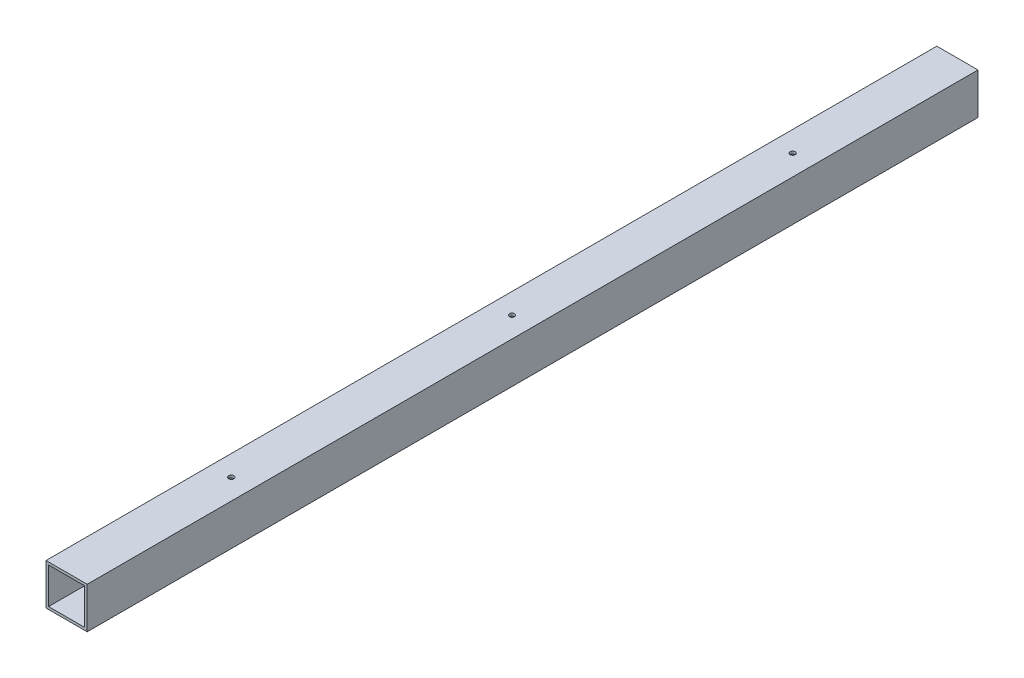
from build123d import *

# Parameters (mm, degrees)
SKETCH1_W           = 1098.55
SKETCH1_H           = 50.8
BOSS_EXTRUDE1_DEPTH = 50.8
SKETCH2_W           = 44.45
SKETCH2_H           = 44.45
CUT_EXTRUDE1_DEPTH  = 1099.55
SKETCH5_R           = 3.302
SKETCH5_R_2         = 3.175
CUT_EXTRUDE2_DEPTH  = 50.8


with BuildPart() as part:
    # Sketch1 → Boss-Extrude1 (new body)
    with BuildSketch(Plane(origin=(0, 0, 0), x_dir=(0, 0, -1), z_dir=(1, 0, 0))):
        Rectangle(SKETCH1_W, SKETCH1_H)
    extrude(amount=BOSS_EXTRUDE1_DEPTH)

    # Sketch2 → Cut-Extrude1 (cut, through all)
    with BuildSketch(Plane.XY.offset(549.275)):
        with Locations((25.4, 0)):
            Rectangle(SKETCH2_W, SKETCH2_H)
    extrude(amount=-CUT_EXTRUDE1_DEPTH, mode=Mode.SUBTRACT)

    # Sketch5 → Cut-Extrude2 (cut)
    with BuildSketch(Plane(origin=(0, 25.4, 0), x_dir=(1, 0, 0), z_dir=(0, 1, 0))):
        with Locations((25.4, -346.075)):
            Circle(SKETCH5_R)
        with Locations((25.4, 0)):
            Circle(SKETCH5_R_2)
        with Locations((25.4, 346.075)):
            Circle(SKETCH5_R_2)
    extrude(amount=-CUT_EXTRUDE2_DEPTH, mode=Mode.SUBTRACT)


solid = part.part
